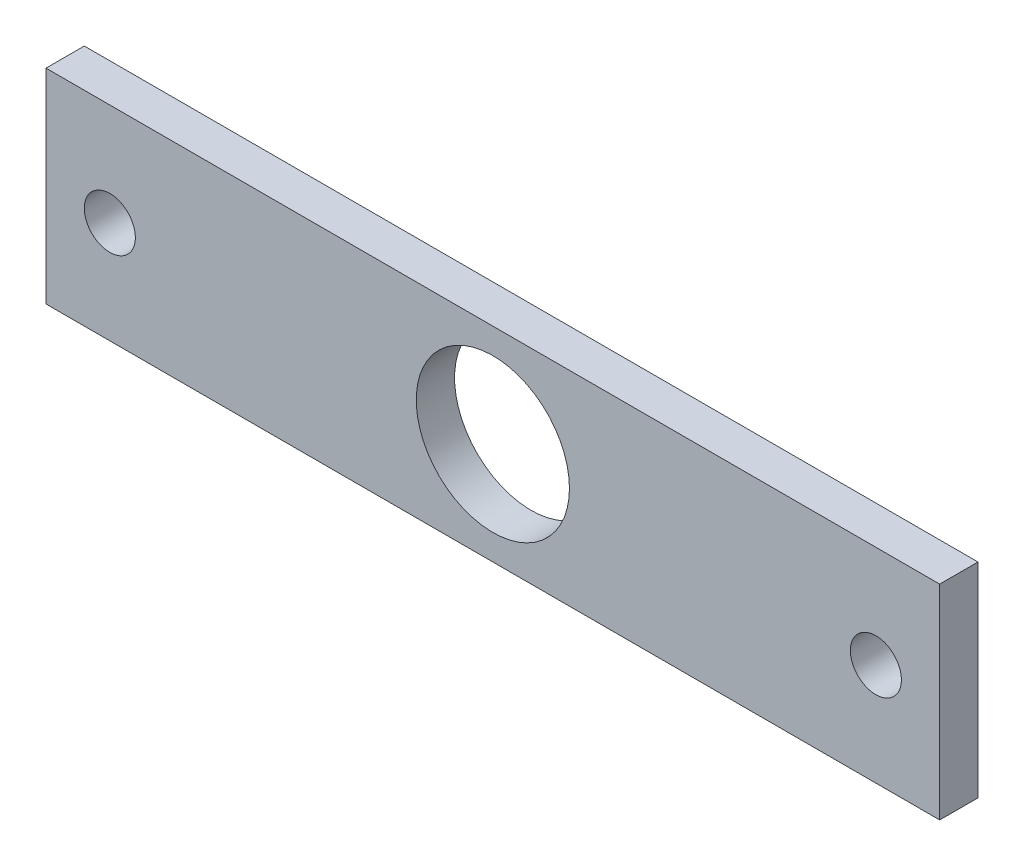
from build123d import *

# Parameters (mm, degrees)
CROQUIS1_W              = 350
CROQUIS1_H              = 80
CROQUIS1_R              = 30
CROQUIS1_R_2            = 10
SALIENTE_EXTRUIR1_DEPTH = 15


with BuildPart() as part:
    # Croquis1 → Saliente-Extruir1 (new body)
    with BuildSketch(Plane.XY):
        Rectangle(CROQUIS1_W, CROQUIS1_H)
        Circle(CROQUIS1_R, mode=Mode.SUBTRACT)
        with Locations((150, 0)):
            Circle(CROQUIS1_R_2, mode=Mode.SUBTRACT)
        with Locations((-150, 0)):
            Circle(CROQUIS1_R_2, mode=Mode.SUBTRACT)
    extrude(amount=-SALIENTE_EXTRUIR1_DEPTH)


solid = part.part
